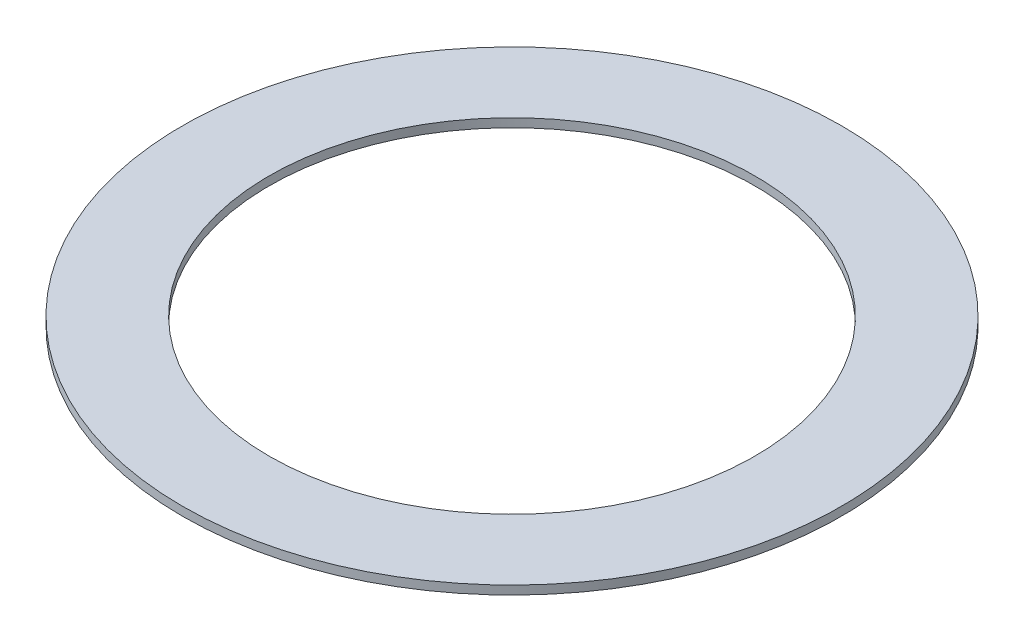
from build123d import *

# Parameters (mm, degrees)
SKETCH1_R           = 120.65
SKETCH1_R_2         = 88.9
BOSS_EXTRUDE1_DEPTH = 3.175


with BuildPart() as part:
    # Sketch1 → Boss-Extrude1 (new body)
    with BuildSketch(Plane(origin=(0, 0, 0), x_dir=(1, 0, 0), z_dir=(0, 1, 0))):
        Circle(SKETCH1_R)
        Circle(SKETCH1_R_2, mode=Mode.SUBTRACT)
    extrude(amount=BOSS_EXTRUDE1_DEPTH)


solid = part.part
